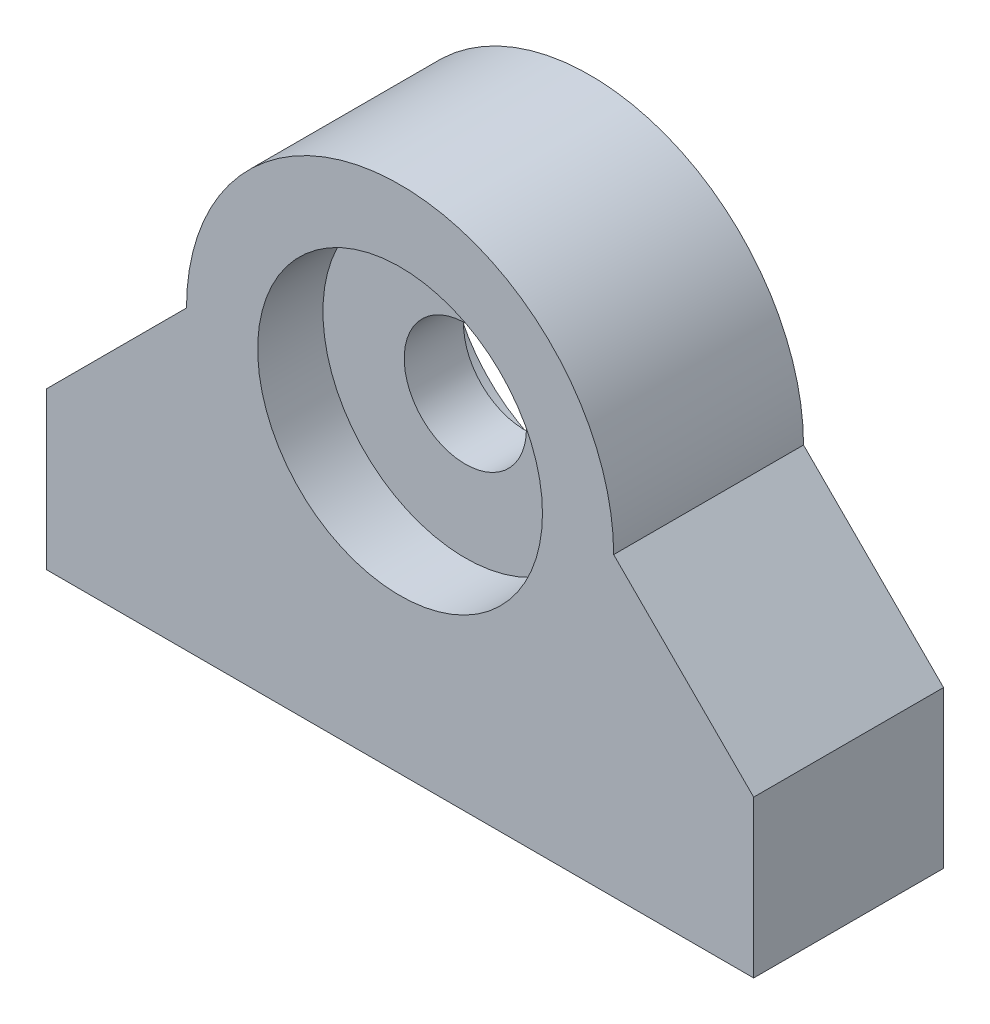
from build123d import *

# Parameters (mm, degrees)
SKETCH1_R                = 7.62
BOSS_EXTRUDE1_DEPTH      = 10.16
SKETCH3_R                = 8.7376
SKETCH3_R_2              = 3.27025
BOSS_EXTRUDE2_DEPTH      = 1.5875
BOSS_EXTRUDE2_DEPTH_BACK = 1.5875
SKETCH4_R                = 1.98374
CUT_EXTRUDE1_DEPTH       = 10.16


with BuildPart() as part:
    # Sketch1 → Boss-Extrude1 (new body)
    with BuildSketch(Plane.XY):
        with BuildLine():
            Line((0, 0), (-18.923, 0))
            Line((-18.923, 0), (-18.923, 8.382))
            Line((-18.923, 8.382), (-11.43, 15.875))
            ThreePointArc((-11.43, 15.875), (0, 27.305), (11.43, 15.875))
            Line((11.43, 15.875), (18.923, 8.382))
            Line((18.923, 8.382), (18.923, 0))
            Line((18.923, 0), (0, 0))
        make_face()
        with Locations((0, 15.875)):
            Circle(SKETCH1_R, mode=Mode.SUBTRACT)
    extrude(amount=BOSS_EXTRUDE1_DEPTH)

    # Sketch3 → Boss-Extrude2 (add, two sides)
    with BuildSketch(Plane.XY.offset(5.08)) as boss_extrude2_sk:
        with Locations((0, 15.875)):
            Circle(SKETCH3_R)
        with Locations((0, 15.875)):
            Circle(SKETCH3_R_2, mode=Mode.SUBTRACT)
    extrude(amount=BOSS_EXTRUDE2_DEPTH)
    extrude(boss_extrude2_sk.sketch, amount=-BOSS_EXTRUDE2_DEPTH_BACK)

    # Sketch4 → Cut-Extrude1 (cut)
    with BuildSketch(Plane(origin=(0, 0, 0), x_dir=(-1, 0, 0), z_dir=(0, -1, 0))):
        with Locations((-10.16, -5.08)):
            Circle(SKETCH4_R)
        with Locations((10.16, -5.08)):
            Circle(SKETCH4_R)
    extrude(amount=-CUT_EXTRUDE1_DEPTH, mode=Mode.SUBTRACT)


solid = part.part
